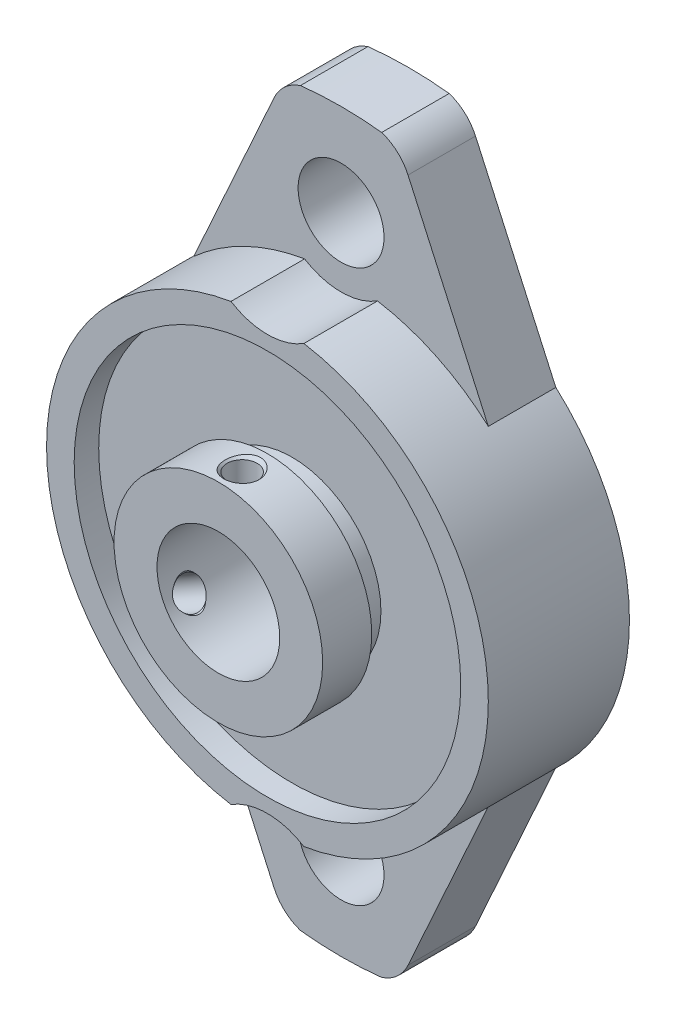
from build123d import *

# Parameters (mm, degrees)
CUT_EXTRUDE_1_DEPTH      = 15.5
CUT_EXTRUDE_1_DEPTH_BACK = 15.5
SKETCH_2_W               = 144
SKETCH_2_H               = 240


with BuildPart() as part:
    # 草图1 → 旋转1 (revolve)
    with BuildSketch(Plane(origin=(0, 0, 0), x_dir=(0, 0, -1), z_dir=(1, 0, 0))):
        with BuildLine():
            Line((-7.75, 8.5), (-7.75, 5))
            Line((-7.75, 5), (6.25, 5))
            Line((6.25, 5), (6.25, 7.2))
            ThreePointArc((6.25, 7.2), (6.2, 7.25), (6.25, 7.3))
            Line((6.25, 7.3), (6.25, 15.75))
            Line((6.25, 15.75), (7.75, 15.75))
            Line((7.75, 15.75), (7.75, 30))
            Line((7.75, 30), (2.25, 30))
            Line((2.25, 30), (2.25, 18))
            Line((2.25, 18), (-3.75, 18))
            Line((-3.75, 18), (-3.75, 15.75))
            Line((-3.75, 15.75), (-1.75, 15.75))
            Line((-1.75, 15.75), (-1.75, 7.25))
            Line((-1.75, 7.25), (-3.75, 7.25))
            Line((-3.75, 7.25), (-3.75, 8.5))
            Line((-3.75, 8.5), (-7.75, 8.5))
        make_face()
    revolve(axis=Axis((0, 0, -7.75), (0, 0, 1)))

    # 草图2 → 切除-拉伸1 (cut, two sides: drawn at the far end of the back side and taken through both)
    with BuildSketch(Plane.XY.offset(-CUT_EXTRUDE_1_DEPTH_BACK)):
        Rectangle(SKETCH_2_W, SKETCH_2_H)
        with BuildLine():
            Line((-12, -13.416407865), (-5.457214514, -27.883459321))
            ThreePointArc((-5.457214514, -27.883459321), (-4.128933976, -29.424934177), (-2.177069938, -30))
            Line((-2.177069938, -30), (2.177069938, -30))
            ThreePointArc((2.177069938, -30), (4.128933976, -29.424934177), (5.457214514, -27.883459321))
            Line((5.457214514, -27.883459321), (12, -13.416407865))
            ThreePointArc((12, -13.416407865), (18, 0), (12, 13.416407865))
            Line((12, 13.416407865), (5.457214514, 27.883459321))
            ThreePointArc((5.457214514, 27.883459321), (4.128933976, 29.424934177), (2.177069938, 30))
            Line((2.177069938, 30), (-2.177069938, 30))
            ThreePointArc((-2.177069938, 30), (-4.128933976, 29.424934177), (-5.457214514, 27.883459321))
            Line((-5.457214514, 27.883459321), (-12, 13.416407865))
            ThreePointArc((-12, 13.416407865), (-18, 0), (-12, -13.416407865))
        make_face(mode=Mode.SUBTRACT)
    extrude(amount=CUT_EXTRUDE_1_DEPTH + CUT_EXTRUDE_1_DEPTH_BACK, mode=Mode.SUBTRACT)

    # 草图3 → 切除-旋转1 (revolve, cut)
    with BuildSketch(Plane(origin=(0, 0, 0), x_dir=(0, 0, -1), z_dir=(1, 0, 0))):
        Polygon((-7.75, 22.5), (-7.75, 28.1), (2.25, 28.1), (2.25, 26), (7.75, 26), (7.75, 22.5), align=None)
    revolve(axis=Axis((0, 22.5, -7.75), (0, 0, 1)), mode=Mode.SUBTRACT)

    # 草图4 → 切除-旋转2 (revolve, cut)
    with BuildSketch(Plane(origin=(0, 0, 0), x_dir=(0, 0, -1), z_dir=(1, 0, 0))):
        Polygon((-7.75, -22.5), (-7.75, -16.9), (2.25, -16.9), (2.25, -19), (7.75, -19), (7.75, -22.5), align=None)
    revolve(axis=Axis((0, -22.5, -7.75), (0, 0, 1)), mode=Mode.SUBTRACT)

    # 草图5 → 切除-旋转3 (revolve, cut)
    with BuildSketch(Plane(origin=(0, 0, 0), x_dir=(0, 0, -1), z_dir=(1, 0, 0))):
        Polygon((-5.8125, 8.5), (-4.3125, 8.5), (-4.583, 8.2295), (-4.583, 4.9205), (-4.3125, 4.65), (-5.8125, 4.65), align=None)
    revolve(axis=Axis((0, 4.65, 5.8125), (0, 1, 0)), mode=Mode.SUBTRACT)

    # 草图6 → 切除-旋转4 (revolve, cut)
    with BuildSketch(Plane.XY.offset(5.8125)):
        Polygon((-4.027018128, -2.325), (-3.277018128, -3.624038106), (-3.646527999, -3.525028234), (-6.51220606, -5.179528234), (-6.611215932, -5.549038106), (-7.361215932, -4.25), align=None)
    revolve(axis=Axis((-7.361215932, -4.25, 5.8125), (0.8660254037844392, 0.4999999999999992, 0)), mode=Mode.SUBTRACT)


solid = part.part
